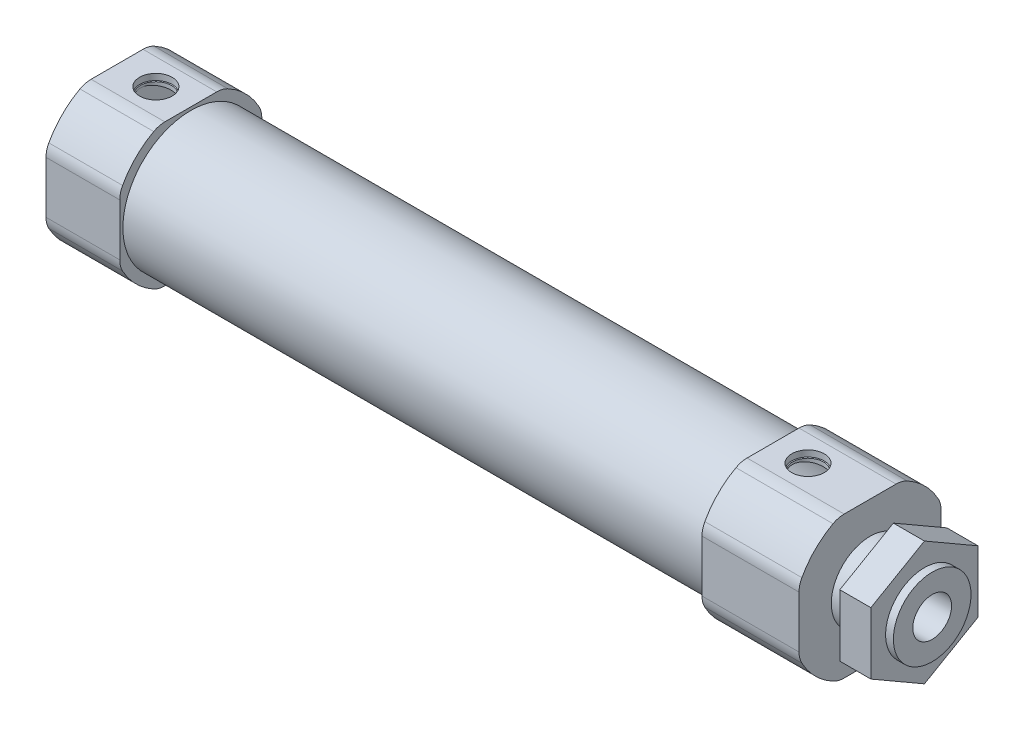
from build123d import *

# Parameters (mm, degrees)
SKETCH_300_R           = 8.75
EXTRUDE_347_DEPTH      = 97
SKETCH_1_R             = 8.75
EXTRUDE_749_DEPTH      = 12.5
SKETCH_1_2_R           = 8.75
EXTRUDE_1213_DEPTH     = 9.5
SKETCH_1_3_R           = 2
CUT_EXTRUDE_1480_DEPTH = 10
HOLE_WIZARD_1519_D     = 4.2
HOLE_WIZARD_1519_DEPTH = 0.8
HOLE_WIZARD_1519_TIP   = 1.2618073
CUT_EXTRUDE_START      = -3
SKETCH_1_4_R           = 8
CUT_EXTRUDE_3_DEPTH    = 91
SKETCH_1_5_R           = 5
EXTRUDE_2592_DEPTH     = 8
CUT_EXTRUDE_2822_REACH = 107
SKETCH_1_6_R           = 2.5
FILLET_2_R             = 3
FILLET_3_R             = 3
EXTRUDE_START          = 3
SKETCH_6_R             = 5
EXTRUDE_1_DEPTH        = 4


with BuildPart() as part:
    # Sketch 300 → Extrude 347 (new body)
    with BuildSketch(Plane(origin=(0, 0, 0), x_dir=(0, 0, -1), z_dir=(1, 0, 0))):
        Circle(SKETCH_300_R)
    extrude(amount=EXTRUDE_347_DEPTH)

    # Sketch 1 → Extrude 749 (add)
    with BuildSketch(Plane(origin=(97, 0, 0), x_dir=(0, 0, -1), z_dir=(1, 0, 0))):
        with BuildLine():
            Line((4.034538387, 9.15), (-4.034538387, 9.15))
            ThreePointArc((-4.034538387, 9.15), (-7.071067812, 7.071067812), (-9.15, 4.034538387))
            Line((-9.15, 4.034538387), (-9.15, -4.034538387))
            ThreePointArc((-9.15, -4.034538387), (-7.071067812, -7.071067812), (-4.034538387, -9.15))
            Line((-4.034538387, -9.15), (4.034538387, -9.15))
            ThreePointArc((4.034538387, -9.15), (7.071067812, -7.071067812), (9.15, -4.034538387))
            Line((9.15, -4.034538387), (9.15, 4.034538387))
            ThreePointArc((9.15, 4.034538387), (7.071067812, 7.071067812), (4.034538387, 9.15))
        make_face()
        Circle(SKETCH_1_R, mode=Mode.SUBTRACT)
    extrude(amount=-EXTRUDE_749_DEPTH)

    # Sketch 1 2 → Extrude 1213 (add)
    with BuildSketch(Plane.ZY):
        with BuildLine():
            Line((4.034538387, 9.15), (-4.034538387, 9.15))
            ThreePointArc((-4.034538387, 9.15), (-7.071067812, 7.071067812), (-9.15, 4.034538387))
            Line((-9.15, 4.034538387), (-9.15, -4.034538387))
            ThreePointArc((-9.15, -4.034538387), (-7.071067812, -7.071067812), (-4.034538387, -9.15))
            Line((-4.034538387, -9.15), (4.034538387, -9.15))
            ThreePointArc((4.034538387, -9.15), (7.071067812, -7.071067812), (9.15, -4.034538387))
            Line((9.15, -4.034538387), (9.15, 4.034538387))
            ThreePointArc((9.15, 4.034538387), (7.071067812, 7.071067812), (4.034538387, 9.15))
        make_face()
        Circle(SKETCH_1_2_R, mode=Mode.SUBTRACT)
    extrude(amount=-EXTRUDE_1213_DEPTH)

    # Sketch 1 3 → Cut-Extrude 1480 (cut)
    with BuildSketch(Plane(origin=(0, 9.15, 0), x_dir=(1, 0, 0), z_dir=(0, 1, 0))):
        with Locations((5, 0)):
            Circle(SKETCH_1_3_R)
        with Locations((89, 0)):
            Circle(SKETCH_1_3_R)
    extrude(amount=-CUT_EXTRUDE_1480_DEPTH, mode=Mode.SUBTRACT)

    # Hole Wizard 1519
    with Locations(Plane(origin=(5, 9.15, 0), x_dir=(0, 0, 1), z_dir=(0, 1, 0))):
        with Locations((0, 0), (0, 84)):
            Hole(HOLE_WIZARD_1519_D / 2, depth=HOLE_WIZARD_1519_DEPTH)
            with Locations((0, 0, -(HOLE_WIZARD_1519_DEPTH + HOLE_WIZARD_1519_TIP / 2))):  # 118° drill point
                Cone(0, HOLE_WIZARD_1519_D / 2, HOLE_WIZARD_1519_TIP, mode=Mode.SUBTRACT)

    # Sketch 1 4 → 切除-拉伸3 (cut)
    with BuildSketch(Plane(origin=(97, 0, 0), x_dir=(0, 0, -1), z_dir=(1, 0, 0)).offset(CUT_EXTRUDE_START)):
        Circle(SKETCH_1_4_R)
    extrude(amount=-CUT_EXTRUDE_3_DEPTH, mode=Mode.SUBTRACT)

    # Sketch 1 5 → Extrude 2592 (add)
    with BuildSketch(Plane(origin=(97, 0, 0), x_dir=(0, 0, -1), z_dir=(1, 0, 0))):
        Circle(SKETCH_1_5_R)
    extrude(amount=EXTRUDE_2592_DEPTH)

    # Sketch 1 6 → Cut-Extrude 2822 (cut, up to next)
    with BuildSketch(Plane(origin=(105, 0, 0), x_dir=(0, 0, -1), z_dir=(1, 0, 0)), mode=Mode.PRIVATE) as cut_extrude_2822_sk1:
        Circle(SKETCH_1_6_R)
    cut_extrude_2822_tool1 = extrude(cut_extrude_2822_sk1.sketch, amount=-CUT_EXTRUDE_2822_REACH, mode=Mode.PRIVATE) & part.part
    add(cut_extrude_2822_tool1.solids().sort_by_distance((105, 0, 0))[0], mode=Mode.SUBTRACT)

    # 圆角2
    fillet_2_edges = [part.edges().sort_by_distance(p)[0] for p in [
        (4.75, 4.034538387, 9.15),
        (4.75, -4.034538387, 9.15),
        (4.75, -9.15, 4.034538387),
        (4.75, -9.15, -4.034538387),
        (4.75, -4.034538387, -9.15),
        (4.75, 4.034538387, -9.15),
        (4.75, 9.15, -4.034538387),
        (4.75, 9.15, 4.034538387),
    ]]
    fillet(fillet_2_edges, radius=FILLET_2_R)

    # 圆角3
    fillet_3_edges = [part.edges().sort_by_distance(p)[0] for p in [
        (90.75, 4.034538387, -9.15),
        (90.75, -4.034538387, -9.15),
        (90.75, -9.15, -4.034538387),
        (90.75, -9.15, 4.034538387),
        (90.75, -4.034538387, 9.15),
        (90.75, 4.034538387, 9.15),
        (90.75, 9.15, 4.034538387),
        (90.75, 9.15, -4.034538387),
    ]]
    fillet(fillet_3_edges, radius=FILLET_3_R)


with BuildPart() as body_2:
    # 草图6 → 凸台-拉伸1 (new body)
    with BuildSketch(Plane(origin=(97, 0, 0), x_dir=(0, 0, -1), z_dir=(1, 0, 0)).offset(EXTRUDE_START)):
        Polygon((0, -7.967433715), (6.9, -3.983716857), (6.9, 3.983716857), (0, 7.967433715), (-6.9, 3.983716857), (-6.9, -3.983716857), align=None)
        Circle(SKETCH_6_R, mode=Mode.SUBTRACT)
    extrude(amount=EXTRUDE_1_DEPTH)


solid = Compound([part.part, body_2.part])
